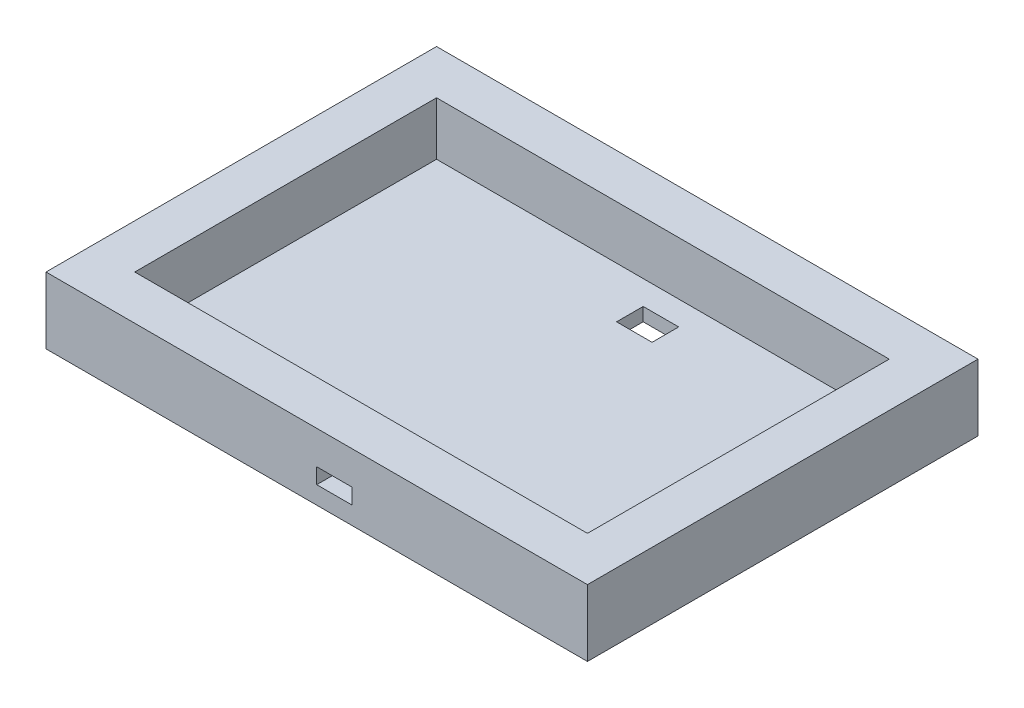
from build123d import *

# Parameters (mm, degrees)
SKETCH2_W                      = 122
SKETCH2_H                      = 88
SKETCH2_W_2                    = 102
SKETCH2_H_2                    = 68
BOSS_EXTRUDE4_DEPTH            = 15
SKETCH3_W                      = 102
SKETCH3_H                      = 68
BOSS_EXTRUDE5_DEPTH            = 3
CUT_EXTRUDE1_REACH             = 90
SKETCH4_W                      = 8
SKETCH4_H                      = 3.5
CUT_EXTRUDE1_DIRECTION_2_DEPTH = 1
SKETCH5_W                      = 8
SKETCH5_H                      = 6
CUT_EXTRUDE2_DEPTH             = 4


with BuildPart() as part:
    # Sketch2 → Boss-Extrude4 (new body)
    with BuildSketch(Plane(origin=(0, 0, 0), x_dir=(1, 0, 0), z_dir=(0, 1, 0))):
        with Locations((-31.608287026, -3.544696319)):
            Rectangle(SKETCH2_W, SKETCH2_H)
        with Locations((-31.608287026, -3.544696319)):
            Rectangle(SKETCH2_W_2, SKETCH2_H_2, mode=Mode.SUBTRACT)
    extrude(amount=BOSS_EXTRUDE4_DEPTH)

    # Sketch3 → Boss-Extrude5 (add)
    with BuildSketch(Plane(origin=(0, 0, 0), x_dir=(1, 0, 0), z_dir=(0, 1, 0))):
        with Locations((-31.608287026, -3.544696319)):
            Rectangle(SKETCH3_W, SKETCH3_H)
    extrude(amount=BOSS_EXTRUDE5_DEPTH)

    # Sketch4 → Cut-Extrude1 (cut, up to next)
    with BuildSketch(Plane.XY.offset(47.544696319), mode=Mode.PRIVATE) as cut_extrude1_sk1:
        with Locations((-27.608287026, 5.75)):
            Rectangle(SKETCH4_W, SKETCH4_H)
    cut_extrude1_tool1 = extrude(cut_extrude1_sk1.sketch, amount=-CUT_EXTRUDE1_REACH, mode=Mode.PRIVATE) & part.part
    add(cut_extrude1_tool1.solids().sort_by_distance((-27.608287, 5.75, 47.544696))[0], mode=Mode.SUBTRACT)

    # Sketch4 → Cut-Extrude1 direction 2 (cut)
    with BuildSketch(Plane.XY.offset(47.544696319)):
        with Locations((-27.608287026, 5.75)):
            Rectangle(SKETCH4_W, SKETCH4_H)
    extrude(amount=CUT_EXTRUDE1_DIRECTION_2_DEPTH, mode=Mode.SUBTRACT)

    # Sketch5 → Cut-Extrude2 (cut, through all)
    with BuildSketch(Plane(origin=(0, 3, 0), x_dir=(1, 0, 0), z_dir=(0, 1, 0))):
        with Locations((-26.608287026, 22.015303681)):
            Rectangle(SKETCH5_W, SKETCH5_H)
    extrude(amount=-CUT_EXTRUDE2_DEPTH, mode=Mode.SUBTRACT)


solid = part.part
